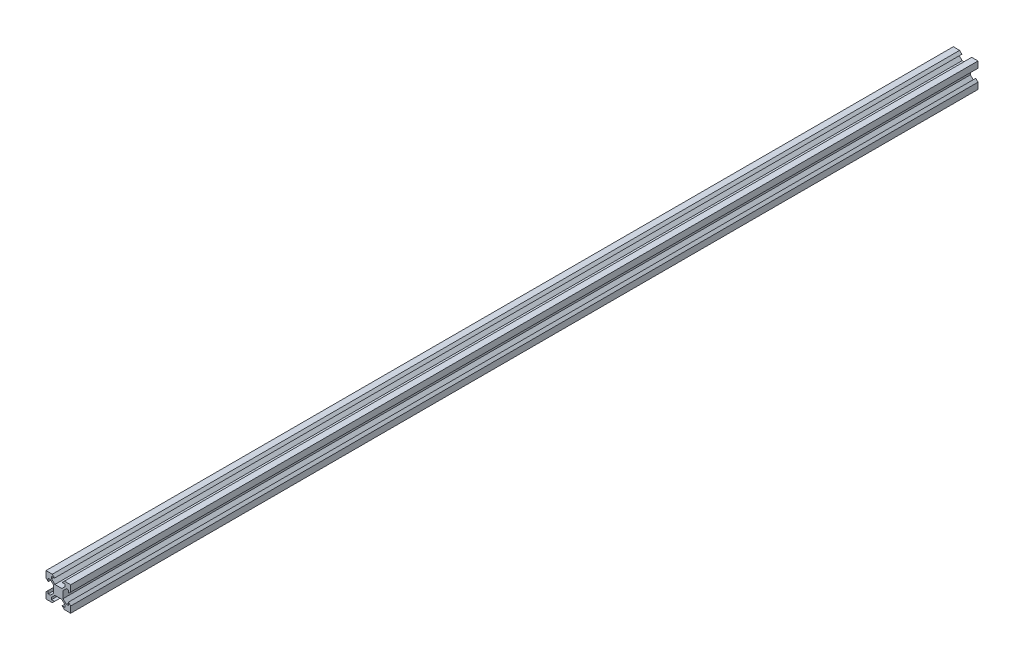
from build123d import *

# Parameters (mm, degrees)
SKETCH1_W           = 20
SKETCH1_H           = 20
BOSS_EXTRUDE1_DEPTH = 735.01
CUT_EXTRUDE1_DEPTH  = 736.01


with BuildPart() as part:
    # Sketch1 → Boss-Extrude1 (new body)
    with BuildSketch(Plane.XY):
        with Locations((10, 10)):
            Rectangle(SKETCH1_W, SKETCH1_H)
    extrude(amount=BOSS_EXTRUDE1_DEPTH)

    # Sketch2 → Cut-Extrude1 (cut, through all)
    with BuildSketch(Plane.XY.offset(735.01)):
        Polygon((4.5, 18.18), (6.94, 18.18), (5.12, 20), (14.88, 20), (13.06, 18.18), (15.5, 18.18), (15.5, 16.475807358), (12.834192642, 13.81), (7.165807358, 13.81), (4.5, 16.475807358), align=None)
        Polygon((14.88, 0), (13.06, 1.82), (15.5, 1.82), (15.5, 3.524192642), (12.834192642, 6.19), (7.165807358, 6.19), (4.5, 3.524192642), (4.5, 1.82), (6.94, 1.82), (5.12, 0), align=None)
        Polygon((1.82, 4.5), (1.82, 6.94), (0, 5.12), (0, 14.88), (1.82, 13.06), (1.82, 15.5), (3.524192642, 15.5), (6.19, 12.834192642), (6.19, 7.165807358), (3.524192642, 4.5), align=None)
        Polygon((20, 14.88), (18.18, 13.06), (18.18, 15.5), (16.475807358, 15.5), (13.81, 12.834192642), (13.81, 7.165807358), (16.475807358, 4.5), (18.18, 4.5), (18.18, 6.94), (20, 5.12), align=None)
    extrude(amount=-CUT_EXTRUDE1_DEPTH, mode=Mode.SUBTRACT)


solid = part.part
